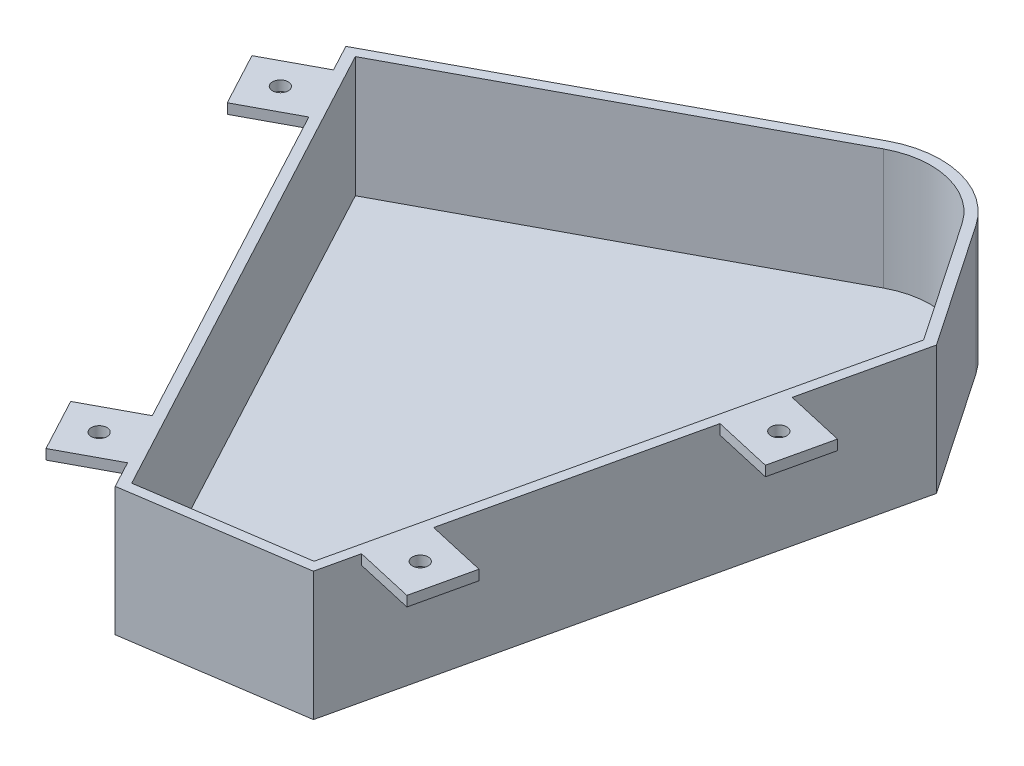
from build123d import *

# Parameters (mm, degrees)
BOSS_EXTRUDE1_DEPTH      = 2.54
BOSS_EXTRUDE5_DEPTH      = 38.1
BOSS_EXTRUDE5_DEPTH_BACK = 2.54
SKETCH6_W                = 19.05
SKETCH6_H                = 3.175
BOSS_EXTRUDE6_DEPTH      = 19.05
SKETCH7_W                = 19.05
SKETCH7_H                = 3.175
BOSS_EXTRUDE7_DEPTH      = 19.05
CUT_EXTRUDE2_REACH       = 5.175
SKETCH8_R                = 2.4892


with BuildPart() as part:
    # Sketch1 → Boss-Extrude1 (new body)
    with BuildSketch(Plane(origin=(0, 0, 0), x_dir=(1, 0, 0), z_dir=(0, 1, 0))):
        with BuildLine():
            Line((108.694500094, 58.18760289), (0, 0))
            Line((0, 0), (81.435616874, -152.121813345))
            Line((81.435616874, -152.121813345), (131.633654365, -144.676094857))
            Line((131.633654365, -144.676094857), (167.396796738, 12.253350144))
            Line((167.396796738, 12.253350144), (141.688668345, 50.073487268))
            ThreePointArc((141.688668345, 50.073487268), (126.748044303, 60.459528823), (108.694500094, 58.18760289))
        make_face()
    extrude(amount=BOSS_EXTRUDE1_DEPTH)

    # Sketch2 → Boss-Extrude5 (add, two sides)
    with BuildSketch(Plane(origin=(0, 2.54, 0), x_dir=(1, 0, 0), z_dir=(0, 1, 0))) as boss_extrude5_sk:
        with BuildLine():
            Line((79.691089457, -155.590310016), (-4.297615284, 1.300674006))
            Line((-4.297615284, 1.300674006), (107.196029455, 60.986747535))
            ThreePointArc((107.196029455, 60.986747535), (127.50626669, 63.54266421), (144.314468737, 51.85836746))
            Line((144.314468737, 51.85836746), (170.799497483, 12.895304744))
            Line((170.799497483, 12.895304744), (134.24691646, -147.498214188))
            Line((134.24691646, -147.498214188), (79.691089457, -155.590310016))
        make_face()
        with BuildLine():
            Line((81.435616874, -152.121813345), (0, 0))
            Line((0, 0), (108.694500094, 58.18760289))
            ThreePointArc((108.694500094, 58.18760289), (126.748044303, 60.459528823), (141.688668345, 50.073487268))
            Line((141.688668345, 50.073487268), (167.396796738, 12.253350144))
            Line((167.396796738, 12.253350144), (131.633654365, -144.676094857))
            Line((131.633654365, -144.676094857), (81.435616874, -152.121813345))
        make_face(mode=Mode.SUBTRACT)
    extrude(amount=BOSS_EXTRUDE5_DEPTH)
    extrude(boss_extrude5_sk.sketch, amount=-BOSS_EXTRUDE5_DEPTH_BACK)

    # Sketch6 → Boss-Extrude6 (add)
    with BuildSketch(Plane(origin=(159.573264194, 0, 36.365650604), x_dir=(0.222196249, 0, -0.975001963), z_dir=(0.975001963, 0, 0.222196249))):
        with Locations((2.898955068, 39.0525)):
            Rectangle(SKETCH6_W, SKETCH6_H)
        with Locations((-91.756887063, 39.0525)):
            Rectangle(SKETCH6_W, SKETCH6_H)
    extrude(amount=BOSS_EXTRUDE6_DEPTH)

    # Sketch7 → Boss-Extrude7 (add)
    with BuildSketch(Plane(origin=(-2.799144645, 0, 1.498470639), x_dir=(0.471959256, 0, 0.881620361), z_dir=(-0.881620361, 0, 0.471959256))):
        with Locations((15.875, 39.0525)):
            Rectangle(SKETCH7_W, SKETCH7_H)
        with Locations((155.73253255, 39.0525)):
            Rectangle(SKETCH7_W, SKETCH7_H)
    extrude(amount=BOSS_EXTRUDE7_DEPTH)

    # Sketch8 → Cut-Extrude2 (cut, up to next)
    with BuildSketch(Plane(origin=(0, 37.465, 0), x_dir=(-1, 0, 0), z_dir=(0, -1, 0)), mode=Mode.PRIVATE) as cut_extrude2_sk1:
        with Locations((3.704225384, -19.989605782)):
            Circle(SKETCH8_R)
    cut_extrude2_tool1 = extrude(cut_extrude2_sk1.sketch, amount=-CUT_EXTRUDE2_REACH, mode=Mode.PRIVATE) & part.part
    add(cut_extrude2_tool1.solids().sort_by_distance((-3.704225, 37.465, 19.989606))[0], mode=Mode.SUBTRACT)
    # Sketch8 → Cut-Extrude2 (cut, up to next)
    with BuildSketch(Plane(origin=(0, 37.465, 0), x_dir=(-1, 0, 0), z_dir=(0, -1, 0)), mode=Mode.PRIVATE) as cut_extrude2_sk2:
        with Locations((-62.302831686, -143.290854064)):
            Circle(SKETCH8_R)
    cut_extrude2_tool2 = extrude(cut_extrude2_sk2.sketch, amount=-CUT_EXTRUDE2_REACH, mode=Mode.PRIVATE) & part.part
    add(cut_extrude2_tool2.solids().sort_by_distance((62.302832, 37.465, 143.290854))[0], mode=Mode.SUBTRACT)
    # Sketch8 → Cut-Extrude2 (cut, up to next)
    with BuildSketch(Plane(origin=(0, 37.465, 0), x_dir=(-1, 0, 0), z_dir=(0, -1, 0)), mode=Mode.PRIVATE) as cut_extrude2_sk3:
        with Locations((-148.472121782, -127.945214839)):
            Circle(SKETCH8_R)
    cut_extrude2_tool3 = extrude(cut_extrude2_sk3.sketch, amount=-CUT_EXTRUDE2_REACH, mode=Mode.PRIVATE) & part.part
    add(cut_extrude2_tool3.solids().sort_by_distance((148.472122, 37.465, 127.945215))[0], mode=Mode.SUBTRACT)
    # Sketch8 → Cut-Extrude2 (cut, up to next)
    with BuildSketch(Plane(origin=(0, 37.465, 0), x_dir=(-1, 0, 0), z_dir=(0, -1, 0)), mode=Mode.PRIVATE) as cut_extrude2_sk4:
        with Locations((-169.504294829, -35.655582993)):
            Circle(SKETCH8_R)
    cut_extrude2_tool4 = extrude(cut_extrude2_sk4.sketch, amount=-CUT_EXTRUDE2_REACH, mode=Mode.PRIVATE) & part.part
    add(cut_extrude2_tool4.solids().sort_by_distance((169.504295, 37.465, 35.655583))[0], mode=Mode.SUBTRACT)


solid = part.part
